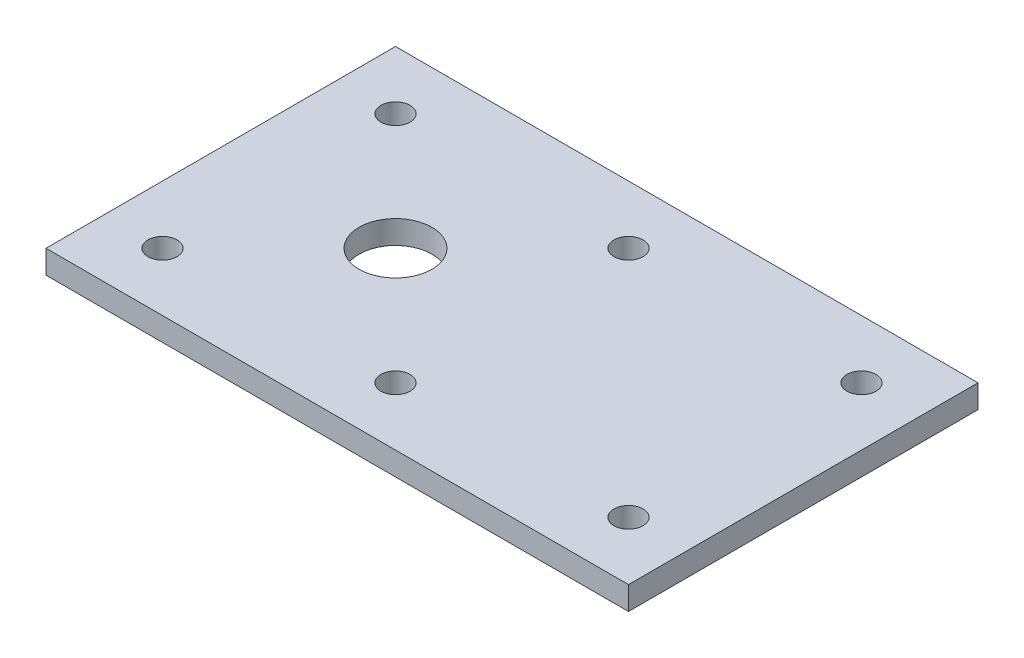
from build123d import *

# Parameters (mm, degrees)
SKETCH1_W            = 200
SKETCH1_H            = 120
BOSS_EXTRUDE1_DEPTH  = 8
SKETCH2_R            = 5
CUT_EXTRUDE1_DEPTH   = 9
LPATTERN1_COUNT      = 2
LPATTERN1_PITCH      = 80
LPATTERN1_COUNT_DIR2 = 3
LPATTERN1_PITCH_DIR2 = 80
SKETCH3_R            = 12.5
CUT_EXTRUDE2_DEPTH   = 9


with BuildPart() as part:
    # Sketch1 → Boss-Extrude1 (new body)
    with BuildSketch(Plane(origin=(0, 0, 0), x_dir=(1, 0, 0), z_dir=(0, 1, 0))):
        with Locations((40, 0)):
            Rectangle(SKETCH1_W, SKETCH1_H)
    extrude(amount=BOSS_EXTRUDE1_DEPTH)

    # Sketch2 → Cut-Extrude1 (cut, through all)
    with BuildSketch(Plane(origin=(0, 8, 0), x_dir=(1, 0, 0), z_dir=(0, 1, 0))):
        with Locations((-40, 40)):
            Circle(SKETCH2_R)
    cut_extrude1 = extrude(amount=-CUT_EXTRUDE1_DEPTH, mode=Mode.SUBTRACT)

    # LPattern1: Cut-Extrude1 2 × 3
    with Locations(*[(j * LPATTERN1_PITCH_DIR2, 0, i * LPATTERN1_PITCH) for i in range(LPATTERN1_COUNT) for j in range(LPATTERN1_COUNT_DIR2) if (i, j) != (0, 0)]):
        add(cut_extrude1, mode=Mode.SUBTRACT)

    # Sketch3 → Cut-Extrude2 (cut, through all)
    with BuildSketch(Plane(origin=(0, 8, 0), x_dir=(1, 0, 0), z_dir=(0, 1, 0))):
        Circle(SKETCH3_R)
    extrude(amount=-CUT_EXTRUDE2_DEPTH, mode=Mode.SUBTRACT)


solid = part.part
